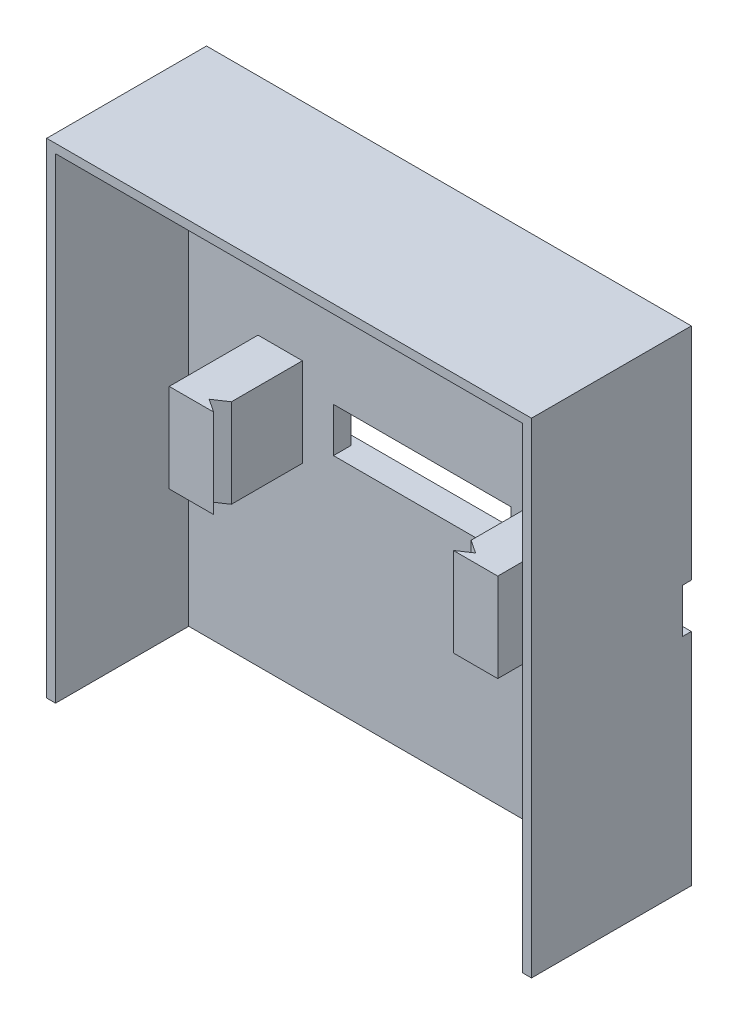
from build123d import *

# Parameters (mm, degrees)
SKICA1_W                 = 54.6
SKICA1_H                 = 54.6
P_IDAT_VYSUNUT_M2_DEPTH  = 3
SKICA4_W                 = 20
SKICA4_H                 = 5
ODEBRAT_VYSUNUT_M1_DEPTH = 2
SKICA5_W                 = 54.6
SKICA5_H                 = 5
ODEBRAT_VYSUNUT_M3_DEPTH = 1
SKICA10_W                = 5
SKICA10_H                = 10
P_IDAT_VYSUNUT_M6_DEPTH  = 10
ODEBRAT_VYSUNUT_M6_DEPTH = 10
P_IDAT_VYSUNUT_M9_DEPTH  = 15
SKICA17_R                = 2
ODEBRAT_VYSUNUT_M8_DEPTH = 4


with BuildPart() as part:
    # Skica1 → Přidat vysunutím2 (new body)
    with BuildSketch(Plane.XY):
        Rectangle(SKICA1_W, SKICA1_H)
    extrude(amount=P_IDAT_VYSUNUT_M2_DEPTH)

    # Skica4 → Odebrat vysunutím1 (cut)
    with BuildSketch(Plane.XY.offset(3)):
        Rectangle(SKICA4_W, SKICA4_H)
    extrude(amount=-ODEBRAT_VYSUNUT_M1_DEPTH, mode=Mode.SUBTRACT)

    # Skica5 → Odebrat vysunutím3 (cut)
    with BuildSketch(Plane(origin=(0, 0, 0), x_dir=(-1, 0, 0), z_dir=(0, 0, -1))):
        Rectangle(SKICA5_W, SKICA5_H)
    extrude(amount=-ODEBRAT_VYSUNUT_M3_DEPTH, mode=Mode.SUBTRACT)

    # Skica10 → Přidat vysunutím6 (add)
    with BuildSketch(Plane.XY.offset(3)):
        with Locations((-16, 0)):
            Rectangle(SKICA10_W, SKICA10_H)
        with Locations((16, 0)):
            Rectangle(SKICA10_W, SKICA10_H)
    extrude(amount=P_IDAT_VYSUNUT_M6_DEPTH)

    # Skica12 → Odebrat vysunutím6 (cut)
    with BuildSketch(Plane(origin=(0, 5, 0), x_dir=(1, 0, 0), z_dir=(0, 1, 0))):
        Polygon((-13.5, -13), (-13.5, -11), (-15, -12), align=None)
        Polygon((13.5, -13), (13.5, -11), (15, -12), align=None)
    extrude(amount=-ODEBRAT_VYSUNUT_M6_DEPTH, mode=Mode.SUBTRACT)

    # Skica14 → Přidat vysunutím9 (add)
    with BuildSketch(Plane.XY.offset(3)):
        Polygon((27.3, 27.3), (-27.3, 27.3), (-27.3, -27.3), (-26.3, -27.3), (-26.3, 26.3), (26.3, 26.3), (26.3, -27.3), (27.3, -27.3), align=None)
    extrude(amount=P_IDAT_VYSUNUT_M9_DEPTH)

    # Skica17 → Odebrat vysunutím8 (cut)
    with BuildSketch(Plane(origin=(0, 0, 1), x_dir=(-1, 0, 0), z_dir=(0, 0, -1))):
        with Locations((-18.3, 0)):
            Circle(SKICA17_R)
        with Locations((18.3, 0)):
            Circle(SKICA17_R)
    extrude(amount=-ODEBRAT_VYSUNUT_M8_DEPTH, mode=Mode.SUBTRACT)


solid = part.part
